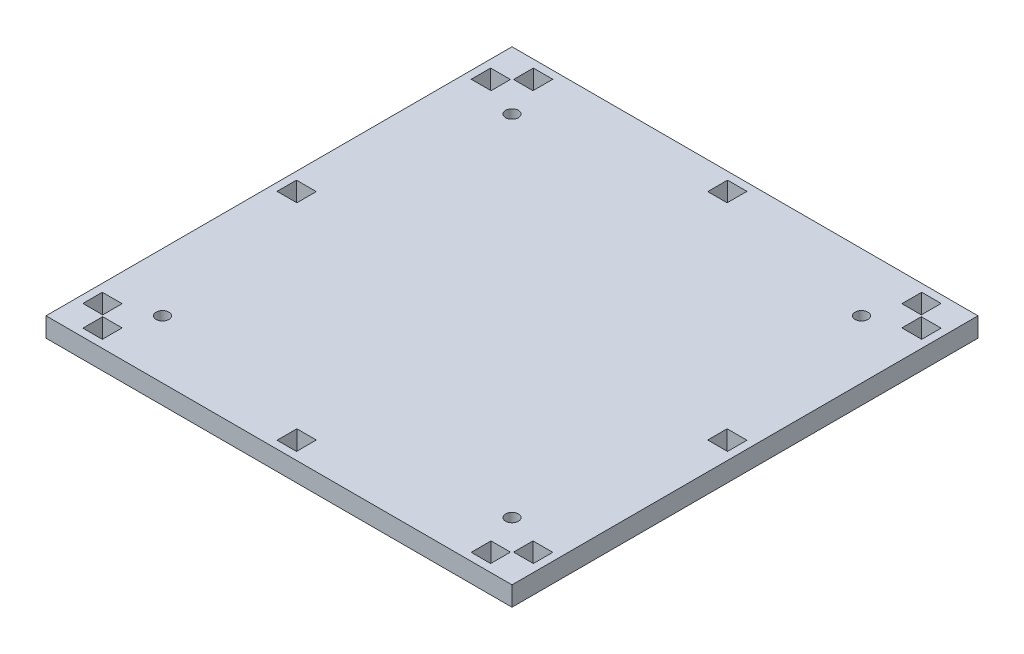
from build123d import *

# Parameters (mm, degrees)
SKETCH1_W                  = 120
SKETCH1_H                  = 120
BOSS_EXTRUDE1_DEPTH        = 5
F_3_3_3_3_DIAMETER_HOLE1_D = 3.3
SKETCH5_W                  = 5.1
SKETCH5_H                  = 5
SKETCH5_W_2                = 5
SKETCH5_H_2                = 5.1
CUT_EXTRUDE1_DEPTH         = 6


with BuildPart() as part:
    # Sketch1 → Boss-Extrude1 (new body)
    with BuildSketch(Plane(origin=(0, 0, 0), x_dir=(1, 0, 0), z_dir=(0, 1, 0))):
        Rectangle(SKETCH1_W, SKETCH1_H)
    extrude(amount=BOSS_EXTRUDE1_DEPTH)

    # Ø3.3 (3.3) Diameter Hole1 (through all)
    with Locations(Plane(origin=(0, 5, 0), x_dir=(1, 0, 0), z_dir=(0, 1, 0))):
        with Locations((-45, 45), (45, 45), (45, -45), (-45, -45)):
            Hole(F_3_3_3_3_DIAMETER_HOLE1_D / 2)

    # Sketch5 → Cut-Extrude1 (cut, through all)
    with BuildSketch(Plane(origin=(0, 5, 0), x_dir=(1, 0, 0), z_dir=(0, 1, 0))):
        with Locations((-55.45, 50)):
            Rectangle(SKETCH5_W, SKETCH5_H)
        with Locations((-55.45, -50)):
            Rectangle(SKETCH5_W, SKETCH5_H)
        with Locations((-50, -55.45)):
            Rectangle(SKETCH5_W_2, SKETCH5_H_2)
        with Locations((50, -55.45)):
            Rectangle(SKETCH5_W_2, SKETCH5_H_2)
        with Locations((-50, 55.45)):
            Rectangle(SKETCH5_W_2, SKETCH5_H_2)
        with Locations((50, 55.45)):
            Rectangle(SKETCH5_W_2, SKETCH5_H_2)
        with Locations((55.45, 50)):
            Rectangle(SKETCH5_W, SKETCH5_H)
        with Locations((55.45, -50)):
            Rectangle(SKETCH5_W, SKETCH5_H)
        with Locations((-55.45, 0)):
            Rectangle(SKETCH5_W, SKETCH5_H)
        with Locations((0, 55.45)):
            Rectangle(SKETCH5_W_2, SKETCH5_H_2)
        with Locations((0, -55.45)):
            Rectangle(SKETCH5_W_2, SKETCH5_H_2)
        with Locations((55.45, 0)):
            Rectangle(SKETCH5_W, SKETCH5_H)
    extrude(amount=-CUT_EXTRUDE1_DEPTH, mode=Mode.SUBTRACT)


solid = part.part
